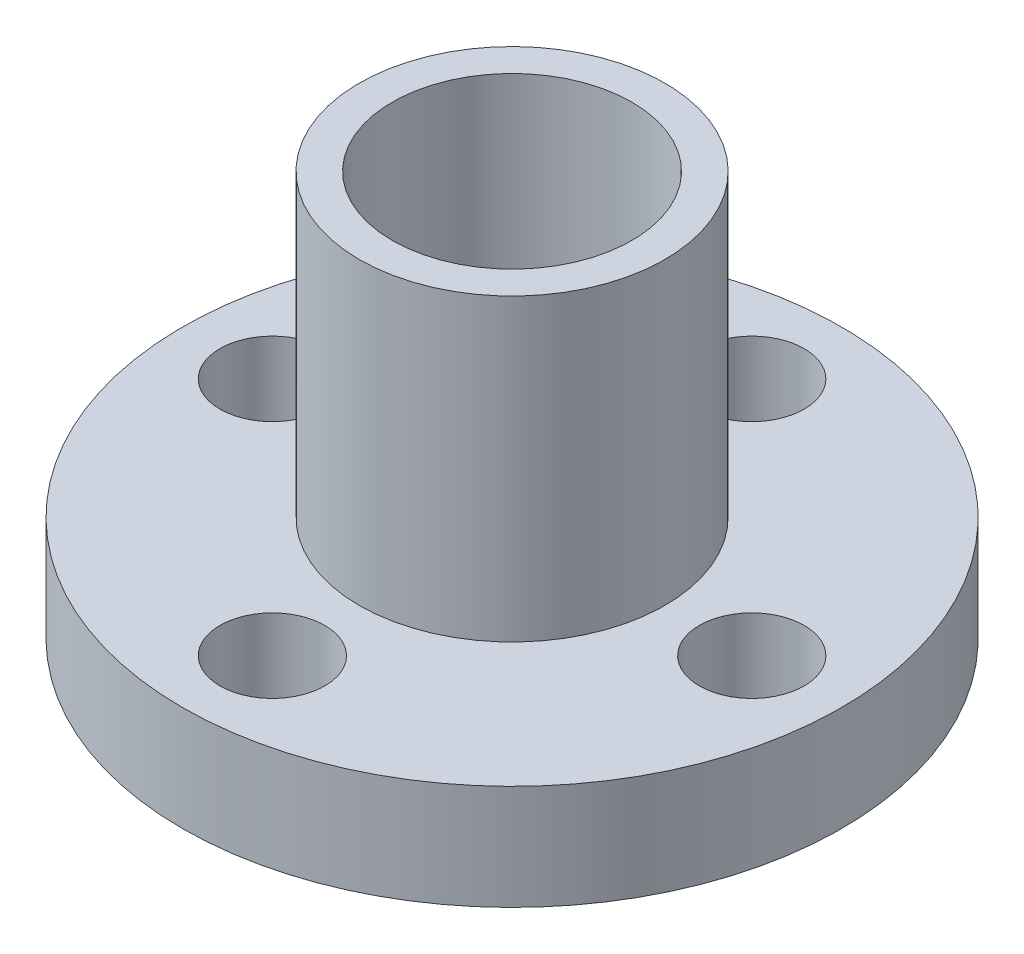
from build123d import *

# Parameters (mm, degrees)
SKETCH_2_R           = 5.1
EXTRUDE_2_DEPTH      = 10
EXTRUDE_2_DEPTH_BACK = 5
SKETCH_1_R           = 11
EXTRUDE_3_DEPTH      = 3.5
SKETCH_3_R           = 1.75
CUT_EXTRUDE_1_DEPTH  = 5.5
SKETCH_4_R           = 4
CUT_EXTRUDE_2_DEPTH  = 16.5


with BuildPart() as part:
    # 草图2 → 凸台-拉伸2 (new body, two sides)
    with BuildSketch(Plane(origin=(0, 0, 0), x_dir=(1, 0, 0), z_dir=(0, 1, 0))) as extrude_2_sk:
        Circle(SKETCH_2_R)
    extrude(amount=EXTRUDE_2_DEPTH)
    extrude(extrude_2_sk.sketch, amount=-EXTRUDE_2_DEPTH_BACK)

    # 草图1 → 凸台-拉伸3 (add)
    with BuildSketch(Plane(origin=(0, 0, 0), x_dir=(1, 0, 0), z_dir=(0, 1, 0))):
        Circle(SKETCH_1_R)
    extrude(amount=-EXTRUDE_3_DEPTH)

    # 草图3 → 切除-拉伸1 (cut)
    with BuildSketch(Plane(origin=(0, 0, 0), x_dir=(1, 0, 0), z_dir=(0, 1, 0))):
        with Locations((-8, 0)):
            Circle(SKETCH_3_R)
        with Locations((0, 8)):
            Circle(SKETCH_3_R)
        with Locations((8, 0)):
            Circle(SKETCH_3_R)
        with Locations((0, -8)):
            Circle(SKETCH_3_R)
    extrude(amount=-CUT_EXTRUDE_1_DEPTH, mode=Mode.SUBTRACT)

    # 草图4 → 切除-拉伸2 (cut)
    with BuildSketch(Plane(origin=(0, 10, 0), x_dir=(1, 0, 0), z_dir=(0, 1, 0))):
        Circle(SKETCH_4_R)
    extrude(amount=-CUT_EXTRUDE_2_DEPTH, mode=Mode.SUBTRACT)


solid = part.part
